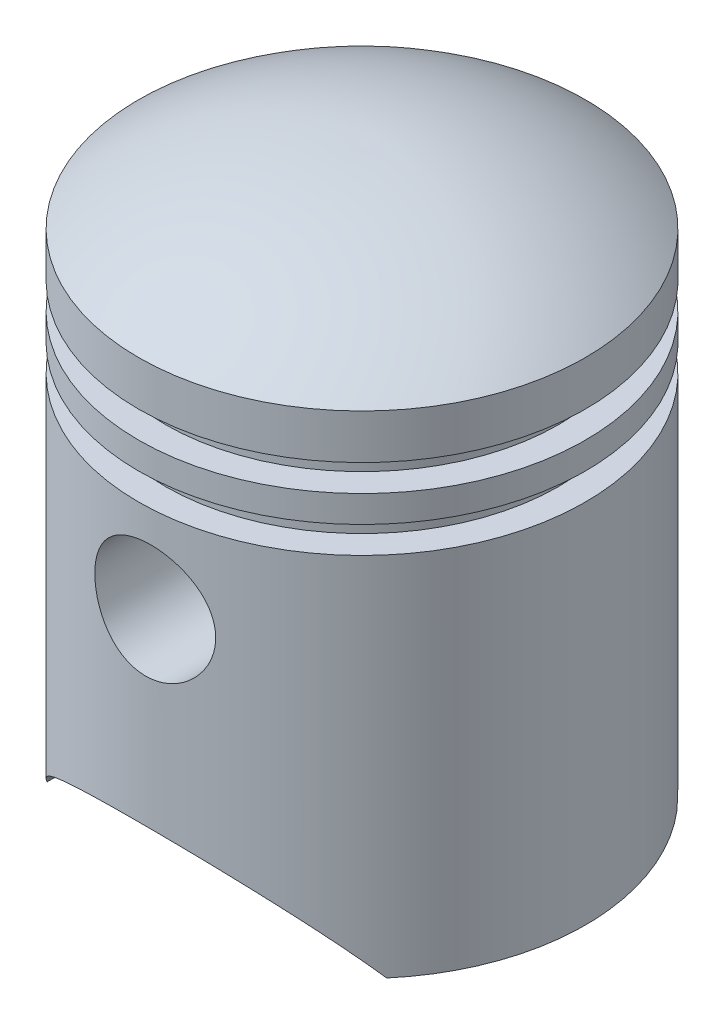
from build123d import *

# Parameters (mm, degrees)
KES_EKSTR_ZYON1_DEPTH            = 25
KES_EKSTR_ZYON1_DEPTH_BACK       = 25
KES_EKSTR_ZYON2_DEPTH            = 25
KES_EKSTR_ZYON2_DEPTH_BACK       = 25
IZIM4_R                          = 6.5
Y_KSEKLIK_EKSTR_ZYON1_REACH      = 79.201
Y_KSEKLIK_EKSTR_ZYON1_END_RADIUS = 23
Y_KSEKLIK_EKSTR_ZYON1_START      = -12
IZIM5_R                          = 7.5
IZIM5_R_2                        = 6.5


with BuildPart() as part:
    # Çizim1 → Döndür39 (revolve)
    with BuildSketch(Plane.XY):
        with BuildLine():
            Line((-16.67359963, -12.856609108), (-16.67359963, 28.143390892))
            Line((-16.67359963, 28.143390892), (-13.67359963, 28.143390892))
            Line((-13.67359963, 28.143390892), (-13.67359963, 31.143390892))
            Line((-13.67359963, 31.143390892), (-16.67359963, 31.143390892))
            Line((-16.67359963, 31.143390892), (-16.67359963, 34.143390892))
            Line((-16.67359963, 34.143390892), (-13.67359963, 34.143390892))
            Line((-13.67359963, 34.143390892), (-13.67359963, 37.143390892))
            Line((-13.67359963, 37.143390892), (-16.67359963, 37.143390892))
            Line((-16.67359963, 37.143390892), (-16.67359963, 42.143390892))
            ThreePointArc((-16.67359963, 42.143390892), (-4.848501321, 48.252458677), (8.32640037, 50.143390892))
            Line((8.32640037, 50.143390892), (8.32640037, 48.143995987))
            Line((8.32640037, 48.143995987), (8.27720674, 48.143995987))
            ThreePointArc((8.27720674, 48.143995987), (-3.766624338, 46.495370879), (-14.67359963, 41.127902037))
            Line((-14.67359963, 41.127902037), (-14.67359963, 39.143390892))
            Line((-14.67359963, 39.143390892), (-11.67359963, 39.143390892))
            Line((-11.67359963, 39.143390892), (-11.67359963, 26.143390892))
            Line((-11.67359963, 26.143390892), (-14.67359963, 26.143390892))
            Line((-14.67359963, 26.143390892), (-14.67359963, -12.856609108))
            Line((-14.67359963, -12.856609108), (-16.67359963, -12.856609108))
        make_face()
    revolve(axis=Axis((8.32640037, 50.143390892, 0), (0, -1, 0)))

    # Çizim3 → Kes-Ekstrüzyon1 (cut, two sides: drawn at the far end of the back side and taken through both)
    with BuildSketch(Plane.XY.offset(-KES_EKSTR_ZYON1_DEPTH_BACK)):
        with BuildLine():
            Line((-10.67359963, -12.856609108), (27.32640037, -12.856609108))
            ThreePointArc((27.32640037, -12.856609108), (8.32640037, -2.856609108), (-10.67359963, -12.856609108))
        make_face()
    extrude(amount=KES_EKSTR_ZYON1_DEPTH + KES_EKSTR_ZYON1_DEPTH_BACK, mode=Mode.SUBTRACT)

    # Çizim4 → Kes-Ekstrüzyon2 (cut, two sides: drawn at the far end of the back side and taken through both)
    with BuildSketch(Plane.XY.offset(-KES_EKSTR_ZYON2_DEPTH_BACK)):
        with Locations((9.310272977, 18.155492789)):
            Circle(IZIM4_R)
    extrude(amount=KES_EKSTR_ZYON2_DEPTH + KES_EKSTR_ZYON2_DEPTH_BACK, mode=Mode.SUBTRACT)

    # Yükseklik-Ekstrüzyon1: up to this cylinder (the profile starts inside it)
    y_kseklik_ekstr_zyon1_end = Plane(origin=(8.32640037, 18.155493, 0), z_dir=(0, 1, 0)) * Cylinder(Y_KSEKLIK_EKSTR_ZYON1_END_RADIUS, 205.402, mode=Mode.PRIVATE)
    # Çizim5 → Yükseklik-Ekstrüzyon1 (add, up to the surface)
    with BuildSketch(Plane.XY.offset(Y_KSEKLIK_EKSTR_ZYON1_START), mode=Mode.PRIVATE) as y_kseklik_ekstr_zyon1_sk1:
        with Locations((9.310272977, 18.155492789)):
            Circle(IZIM5_R)
        with Locations((9.310272977, 18.155492789)):
            Circle(IZIM5_R_2, mode=Mode.SUBTRACT)
    y_kseklik_ekstr_zyon1_tool1 = extrude(y_kseklik_ekstr_zyon1_sk1.sketch, amount=-Y_KSEKLIK_EKSTR_ZYON1_REACH, mode=Mode.PRIVATE) & y_kseklik_ekstr_zyon1_end
    y_kseklik_ekstr_zyon1 = y_kseklik_ekstr_zyon1_tool1.solids().sort_by_distance((2.022405, 18.155493, -12))[0]
    add(y_kseklik_ekstr_zyon1)

    # Aynalama1: Yükseklik-Ekstrüzyon1 across plane
    add(y_kseklik_ekstr_zyon1.mirror(Plane.XY))


solid = part.part
